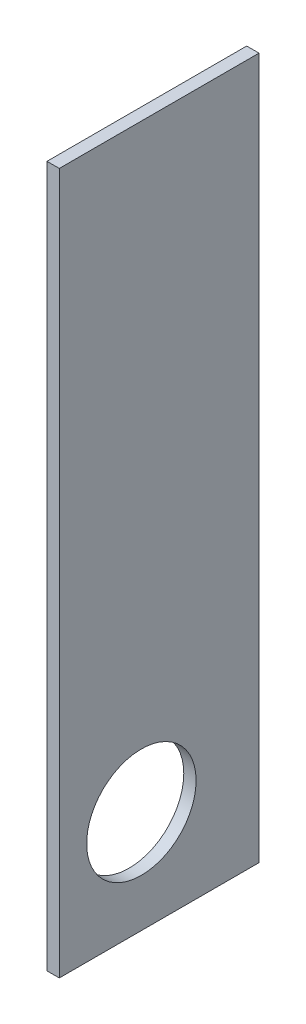
from build123d import *

# Parameters (mm, degrees)
SKETCH1_R           = 80
BOSS_EXTRUDE1_DEPTH = 18


with BuildPart() as part:
    # Sketch1 → Boss-Extrude1 (new body)
    with BuildSketch(Plane(origin=(0, 0, 0), x_dir=(0, 0, -1), z_dir=(1, 0, 0))):
        Polygon((24.392066811, -967.219556499), (-267.607933189, -967.219556499), (-267.607933189, -836.121901092), (-267.607933189, -676.121901092), (-267.607933189, 57.780443501), (24.392066811, 57.780443501), align=None)
        with Locations((-147.607933189, -817.219556499)):
            Circle(SKETCH1_R, mode=Mode.SUBTRACT)
    extrude(amount=BOSS_EXTRUDE1_DEPTH)


solid = part.part
